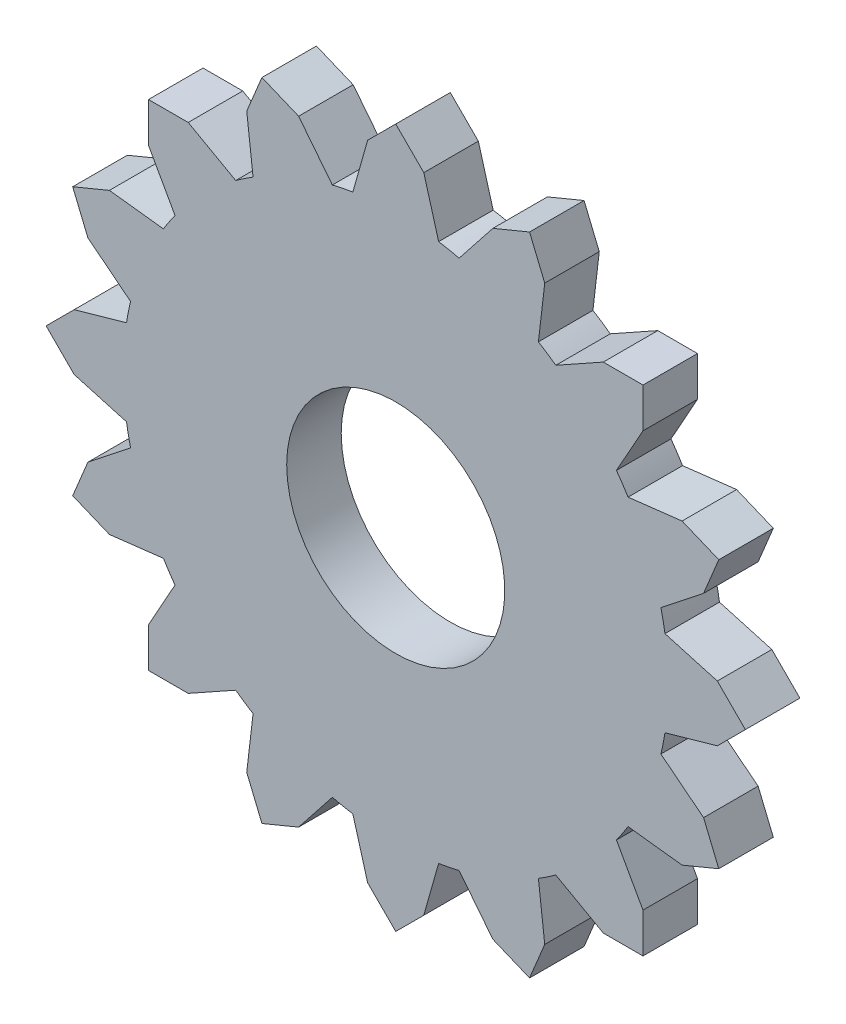
from build123d import *

# Parameters (mm, degrees)
BOSS_EXTRUDE2_DEPTH = 10
SKETCH2_R           = 20
CUT_EXTRUDE1_DEPTH  = 10


with BuildPart() as part:
    # Sketch1 → Boss-Extrude2 (new body)
    with BuildSketch(Plane.XY):
        with BuildLine():
            Line((17.811997012, 56.458001404), (11.62649389, 48.629462673))
            ThreePointArc((11.62649389, 48.629462673), (9.754516101, 49.03926402), (7.86820995, 49.377031828))
            Line((7.86820995, 49.377031828), (5.14940229, 58.976748098))
            Line((5.14940229, 58.976748098), (0, 64.126150387))
            Line((0, 64.126150387), (-5.14940229, 58.976748098))
            Line((-5.14940229, 58.976748098), (-7.86820995, 49.377031828))
            ThreePointArc((-7.86820995, 49.377031828), (-9.754516101, 49.03926402), (-11.62649389, 48.629462673))
            Line((-11.62649389, 48.629462673), (-17.811997012, 56.458001404))
            Line((-17.811997012, 56.458001404), (-24.540015335, 59.244837841))
            Line((-24.540015335, 59.244837841), (-27.326851772, 52.516819519))
            Line((-27.326851772, 52.516819519), (-26.16505015, 42.607395492))
            ThreePointArc((-26.16505015, 42.607395492), (-27.778511651, 41.573480615), (-29.351169429, 40.478498652))
            Line((-29.351169429, 40.478498652), (-38.061681234, 45.34403579))
            Line((-38.061681234, 45.34403579), (-45.34403579, 45.34403579))
            Line((-45.34403579, 45.34403579), (-45.34403579, 38.061681234))
            Line((-45.34403579, 38.061681234), (-40.478498652, 29.351169429))
            ThreePointArc((-40.478498652, 29.351169429), (-41.573480615, 27.778511651), (-42.607395492, 26.16505015))
            Line((-42.607395492, 26.16505015), (-52.516819519, 27.326851772))
            Line((-52.516819519, 27.326851772), (-59.244837841, 24.540015335))
            Line((-59.244837841, 24.540015335), (-56.458001404, 17.811997012))
            Line((-56.458001404, 17.811997012), (-48.629462673, 11.62649389))
            ThreePointArc((-48.629462673, 11.62649389), (-49.03926402, 9.754516101), (-49.377031828, 7.86820995))
            Line((-49.377031828, 7.86820995), (-58.976748098, 5.14940229))
            Line((-58.976748098, 5.14940229), (-64.126150387, 0))
            Line((-64.126150387, 0), (-58.976748098, -5.14940229))
            Line((-58.976748098, -5.14940229), (-49.377031828, -7.86820995))
            ThreePointArc((-49.377031828, -7.86820995), (-49.03926402, -9.754516101), (-48.629462673, -11.62649389))
            Line((-48.629462673, -11.62649389), (-56.458001404, -17.811997012))
            Line((-56.458001404, -17.811997012), (-59.244837841, -24.540015335))
            Line((-59.244837841, -24.540015335), (-52.516819519, -27.326851772))
            Line((-52.516819519, -27.326851772), (-42.607395492, -26.16505015))
            ThreePointArc((-42.607395492, -26.16505015), (-41.573480615, -27.778511651), (-40.478498652, -29.351169429))
            Line((-40.478498652, -29.351169429), (-45.34403579, -38.061681234))
            Line((-45.34403579, -38.061681234), (-45.34403579, -45.34403579))
            Line((-45.34403579, -45.34403579), (-38.061681234, -45.34403579))
            Line((-38.061681234, -45.34403579), (-29.351169429, -40.478498652))
            ThreePointArc((-29.351169429, -40.478498652), (-27.778511651, -41.573480615), (-26.16505015, -42.607395492))
            Line((-26.16505015, -42.607395492), (-27.326851772, -52.516819519))
            Line((-27.326851772, -52.516819519), (-24.540015335, -59.244837841))
            Line((-24.540015335, -59.244837841), (-17.811997012, -56.458001404))
            Line((-17.811997012, -56.458001404), (-11.62649389, -48.629462673))
            ThreePointArc((-11.62649389, -48.629462673), (-9.754516101, -49.03926402), (-7.86820995, -49.377031828))
            Line((-7.86820995, -49.377031828), (-5.14940229, -58.976748098))
            Line((-5.14940229, -58.976748098), (0, -64.126150387))
            Line((0, -64.126150387), (5.14940229, -58.976748098))
            Line((5.14940229, -58.976748098), (7.86820995, -49.377031828))
            ThreePointArc((7.86820995, -49.377031828), (9.754516101, -49.03926402), (11.62649389, -48.629462673))
            Line((11.62649389, -48.629462673), (17.811997012, -56.458001404))
            Line((17.811997012, -56.458001404), (24.540015335, -59.244837841))
            Line((24.540015335, -59.244837841), (27.326851772, -52.516819519))
            Line((27.326851772, -52.516819519), (26.16505015, -42.607395492))
            ThreePointArc((26.16505015, -42.607395492), (27.778511651, -41.573480615), (29.351169429, -40.478498652))
            Line((29.351169429, -40.478498652), (38.061681234, -45.34403579))
            Line((38.061681234, -45.34403579), (45.34403579, -45.34403579))
            Line((45.34403579, -45.34403579), (45.34403579, -38.061681234))
            Line((45.34403579, -38.061681234), (40.478498652, -29.351169429))
            ThreePointArc((40.478498652, -29.351169429), (41.573480615, -27.778511651), (42.607395492, -26.16505015))
            Line((42.607395492, -26.16505015), (52.516819519, -27.326851772))
            Line((52.516819519, -27.326851772), (59.244837841, -24.540015335))
            Line((59.244837841, -24.540015335), (56.458001404, -17.811997012))
            Line((56.458001404, -17.811997012), (48.629462673, -11.62649389))
            ThreePointArc((48.629462673, -11.62649389), (49.03926402, -9.754516101), (49.377031828, -7.86820995))
            Line((49.377031828, -7.86820995), (58.976748098, -5.14940229))
            Line((58.976748098, -5.14940229), (64.126150387, 0))
            Line((64.126150387, 0), (58.976748098, 5.14940229))
            Line((58.976748098, 5.14940229), (49.377031828, 7.86820995))
            ThreePointArc((49.377031828, 7.86820995), (49.03926402, 9.754516101), (48.629462673, 11.62649389))
            Line((48.629462673, 11.62649389), (56.458001404, 17.811997012))
            Line((56.458001404, 17.811997012), (59.244837841, 24.540015335))
            Line((59.244837841, 24.540015335), (52.516819519, 27.326851772))
            Line((52.516819519, 27.326851772), (42.607395492, 26.16505015))
            ThreePointArc((42.607395492, 26.16505015), (41.573480615, 27.778511651), (40.478498652, 29.351169429))
            Line((40.478498652, 29.351169429), (45.34403579, 38.061681234))
            Line((45.34403579, 38.061681234), (45.34403579, 45.34403579))
            Line((45.34403579, 45.34403579), (38.061681234, 45.34403579))
            Line((38.061681234, 45.34403579), (29.351169429, 40.478498652))
            ThreePointArc((29.351169429, 40.478498652), (27.778511651, 41.573480615), (26.16505015, 42.607395492))
            Line((26.16505015, 42.607395492), (27.326851772, 52.516819519))
            Line((27.326851772, 52.516819519), (24.540015335, 59.244837841))
            Line((24.540015335, 59.244837841), (17.811997012, 56.458001404))
        make_face()
    extrude(amount=BOSS_EXTRUDE2_DEPTH)

    # Sketch2 → Cut-Extrude1 (cut)
    with BuildSketch(Plane(origin=(0, 0, 0), x_dir=(-1, 0, 0), z_dir=(0, 0, -1))):
        Circle(SKETCH2_R)
    extrude(amount=-CUT_EXTRUDE1_DEPTH, mode=Mode.SUBTRACT)


solid = part.part
